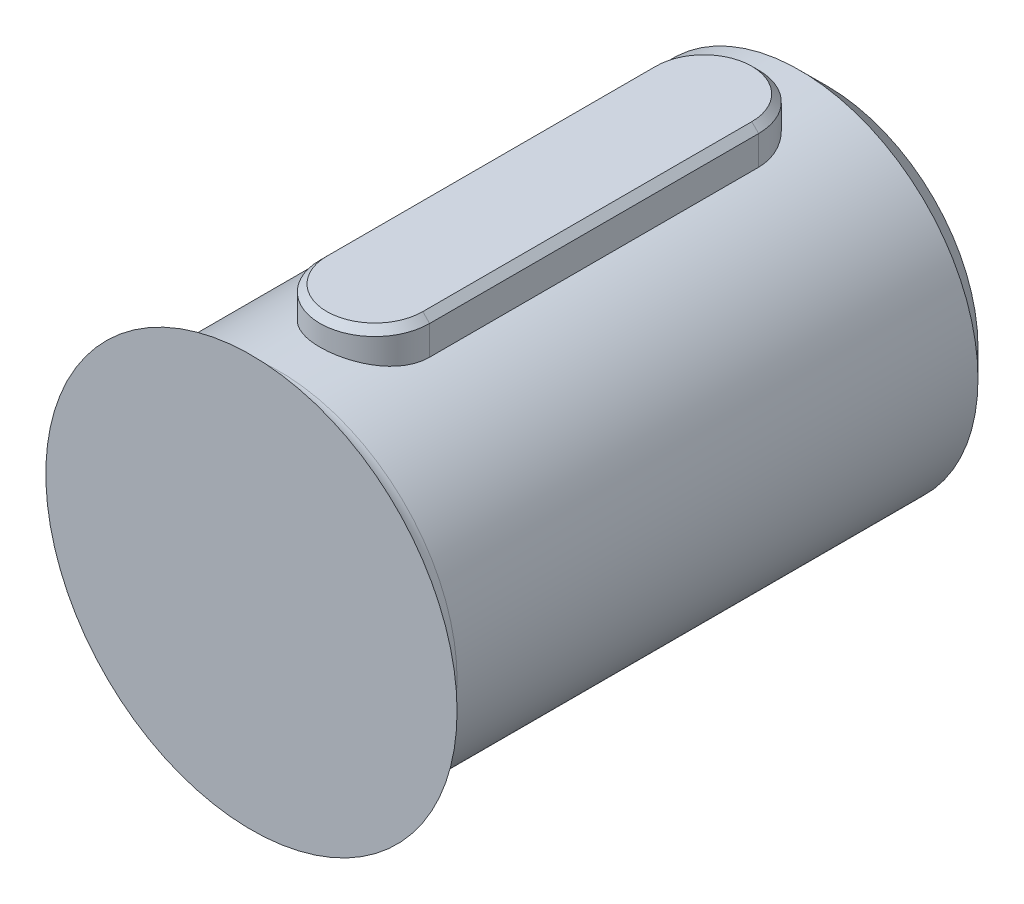
from build123d import *

# Parameters (mm, degrees)
SKETCH_1_R          = 41.275
EXTRUDE_1_DEPTH     = 5
SKETCH_5_R          = 13
EXTRUDE_5_DEPTH     = 42
CHAMFER_3_SIZE      = 2
FILLET_1_R          = 2
EXTRUDE_START       = -0.630683
EXTRUDE_7_DEPTH     = 2.630683
CHAMFER_4_SIZE      = 0.5
SKETCH_11_R         = 65.391227149
CUT_EXTRUDE_1_DEPTH = 5


with BuildPart() as part:
    # 草图1 → 凸台-拉伸1 (new body)
    with BuildSketch(Plane.XY):
        Circle(SKETCH_1_R)
    extrude(amount=EXTRUDE_1_DEPTH)

    # 草图5 → 凸台-拉伸5 (add)
    with BuildSketch(Plane(origin=(0, 0, 0), x_dir=(-1, 0, 0), z_dir=(0, 0, -1))):
        Circle(SKETCH_5_R)
    extrude(amount=EXTRUDE_5_DEPTH)

    # 倒角3
    chamfer_3_edges = [part.edges().sort_by_distance(p)[0] for p in [
        (13, 0, -42),
    ]]
    chamfer(chamfer_3_edges, length=CHAMFER_3_SIZE)

    # 圆角1
    fillet_1_edges = [part.edges().sort_by_distance(p)[0] for p in [
        (13, 0, 0),
    ]]
    fillet(fillet_1_edges, radius=FILLET_1_R)

    # 草图10 → 凸台-拉伸7 (add)
    with BuildSketch(Plane(origin=(0, 13, 0), x_dir=(-1, 0, 0), z_dir=(0, 1, 0)).offset(EXTRUDE_START)):
        with BuildLine():
            Line((-4, -9), (-4, -33))
            ThreePointArc((-4, -33), (0, -37), (4, -33))
            Line((4, -33), (4, -9))
            ThreePointArc((4, -9), (0, -5), (-4, -9))
        make_face()
    extrude(amount=EXTRUDE_7_DEPTH)

    # 倒角4
    chamfer_4_edges = [part.edges().sort_by_distance(p)[0] for p in [
        (0, 15, -37),
        (-4, 15, -21),
        (0, 15, -5),
        (4, 15, -21),
    ]]
    chamfer(chamfer_4_edges, length=CHAMFER_4_SIZE)

    # 草图11 → 切除-拉伸1 (cut)
    with BuildSketch(Plane.XY.offset(5)):
        Circle(SKETCH_11_R)
    extrude(amount=-CUT_EXTRUDE_1_DEPTH, mode=Mode.SUBTRACT)


solid = part.part
